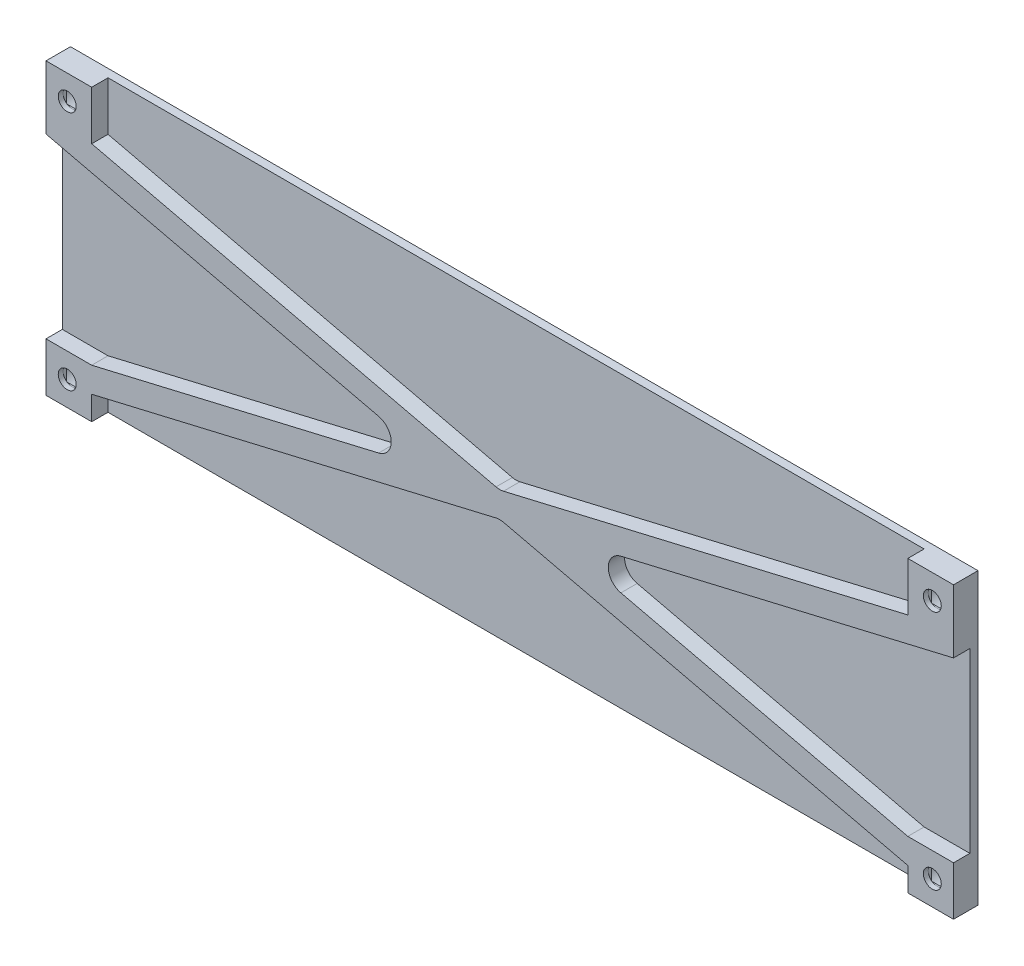
from build123d import *

# Parameters (mm, degrees)
SKETCH1_W                       = 112
SKETCH1_H                       = 35.5
BOSS_EXTRUDE1_DEPTH             = 1
SKETCH2_W                       = 6
SKETCH2_H                       = 6
BOSS_EXTRUDE2_DEPTH             = 2
SKETCH3_R                       = 1.1
CUT_EXTRUDE1_DEPTH              = 4
SKETCH4_R                       = 2
CUT_EXTRUDE2_DEPTH              = 2
CUT_EXTRUDE3_DEPTH              = 0.2
SKETCH6_W                       = 2.2
SKETCH6_H                       = 2.2
CUT_EXTRUDE4_DEPTH              = 0.2
MIRROR2_COPY_1_DEPTH            = 0.2
MIRROR2_COPY_2_SKETCH_W         = 2.2
MIRROR2_COPY_2_SKETCH_H         = 2.2
MIRROR2_COPY_2_DEPTH            = 0.2
SKETCH7_W                       = 0.4
SKETCH7_H                       = 35.5
CUT_EXTRUDE5_DEPTH              = 4
AUFSATZ_LINEAR_AUSTRAGEN2_DEPTH = 2
VERRUNDUNG1_R                   = 2


with BuildPart() as part:
    # Sketch1 → Boss-Extrude1 (new body)
    with BuildSketch(Plane.XY):
        Rectangle(SKETCH1_W, SKETCH1_H)
    extrude(amount=BOSS_EXTRUDE1_DEPTH)

    # Sketch2 → Boss-Extrude2 (add)
    with BuildSketch(Plane.XY.offset(1)):
        with Locations((-53, 14.75)):
            Rectangle(SKETCH2_W, SKETCH2_H)
        with Locations((-53, -14.75)):
            Rectangle(SKETCH2_W, SKETCH2_H)
        with Locations((53, -14.75)):
            Rectangle(SKETCH2_W, SKETCH2_H)
        with Locations((53, 14.75)):
            Rectangle(SKETCH2_W, SKETCH2_H)
    extrude(amount=BOSS_EXTRUDE2_DEPTH)

    # Sketch3 → Cut-Extrude1 (cut, through all)
    with BuildSketch(Plane.XY.offset(3)):
        with Locations((-53, 14.75)):
            Circle(SKETCH3_R)
        with Locations((-53, -14.75)):
            Circle(SKETCH3_R)
        with Locations((53, -14.75)):
            Circle(SKETCH3_R)
        with Locations((53, 14.75)):
            Circle(SKETCH3_R)
    extrude(amount=-CUT_EXTRUDE1_DEPTH, mode=Mode.SUBTRACT)

    # Sketch4 → Cut-Extrude2 (cut)
    with BuildSketch(Plane(origin=(0, 0, 0), x_dir=(-1, 0, 0), z_dir=(0, 0, -1))):
        with Locations((-53, 14.75)):
            Circle(SKETCH4_R)
        with Locations((-53, -14.75)):
            Circle(SKETCH4_R)
        with Locations((53, 14.75)):
            Circle(SKETCH4_R)
        with Locations((53, -14.75)):
            Circle(SKETCH4_R)
    extrude(amount=-CUT_EXTRUDE2_DEPTH, mode=Mode.SUBTRACT)

    # Sketch5 → Cut-Extrude3 (cut)
    with BuildSketch(Plane(origin=(0, 0, 2), x_dir=(-1, 0, 0), z_dir=(0, 0, -1))):
        with BuildLine():
            Line((-54.1, 13.079670691), (-54.1, 16.420329309))
            ThreePointArc((-54.1, 16.420329309), (-53, 16.75), (-51.9, 16.420329309))
            Line((-51.9, 16.420329309), (-51.9, 13.079670691))
            ThreePointArc((-51.9, 13.079670691), (-53, 12.75), (-54.1, 13.079670691))
        make_face()
    cut_extrude3 = extrude(amount=-CUT_EXTRUDE3_DEPTH, mode=Mode.SUBTRACT)

    # Sketch6 → Cut-Extrude4 (cut)
    with BuildSketch(Plane(origin=(0, 0, 2.2), x_dir=(-1, 0, 0), z_dir=(0, 0, -1))):
        with Locations((-53, 14.75)):
            Rectangle(SKETCH6_W, SKETCH6_H)
    cut_extrude4 = extrude(amount=-CUT_EXTRUDE4_DEPTH, mode=Mode.SUBTRACT)

    # Mirror1: Cut-Extrude3, Cut-Extrude4 across plane
    add(cut_extrude3.mirror(Plane(origin=(0, 0, 0), x_dir=(0, 0, 1), z_dir=(1, 0, 0))), mode=Mode.SUBTRACT)
    add(cut_extrude4.mirror(Plane(origin=(0, 0, 0), x_dir=(0, 0, 1), z_dir=(1, 0, 0))), mode=Mode.SUBTRACT)

    # Mirror2: Cut-Extrude3, Cut-Extrude4 across plane
    add(cut_extrude3.mirror(Plane.ZX), mode=Mode.SUBTRACT)
    add(cut_extrude4.mirror(Plane.ZX), mode=Mode.SUBTRACT)

    # Mirror2 copy 1 sketch → Mirror2 copy 1 (cut)
    with BuildSketch(Plane(origin=(0, 0, 2), x_dir=(1, 0, 0), z_dir=(0, 0, -1))):
        with BuildLine():
            Line((-54.1, 13.079670691), (-54.1, 16.420329309))
            ThreePointArc((-54.1, 16.420329309), (-53, 16.75), (-51.9, 16.420329309))
            Line((-51.9, 16.420329309), (-51.9, 13.079670691))
            ThreePointArc((-51.9, 13.079670691), (-53, 12.75), (-54.1, 13.079670691))
        make_face()
    extrude(amount=-MIRROR2_COPY_1_DEPTH, mode=Mode.SUBTRACT)

    # Mirror2 copy 2 sketch → Mirror2 copy 2 (cut)
    with BuildSketch(Plane(origin=(0, 0, 2.2), x_dir=(1, 0, 0), z_dir=(0, 0, -1))):
        with Locations((-53, 14.75)):
            Rectangle(MIRROR2_COPY_2_SKETCH_W, MIRROR2_COPY_2_SKETCH_H)
    extrude(amount=-MIRROR2_COPY_2_DEPTH, mode=Mode.SUBTRACT)

    # Sketch7 → Cut-Extrude5 (cut, through all)
    with BuildSketch(Plane(origin=(0, 0, 0), x_dir=(-1, 0, 0), z_dir=(0, 0, -1))):
        with Locations((-55.8, 0)):
            Rectangle(SKETCH7_W, SKETCH7_H)
        with Locations((55.8, 0)):
            Rectangle(SKETCH7_W, SKETCH7_H)
    extrude(amount=-CUT_EXTRUDE5_DEPTH, mode=Mode.SUBTRACT)

    # Skizze5 → Aufsatz-Linear austragen2 (add)
    with BuildSketch(Plane.XY.offset(1)):
        Polygon((-50, 11.75), (0, 0), (50, 11.75), (55.6, 11.75), (55.6, 9.984275645), (6.55686033, -1.540862177), (50, -11.75), (50, -14.831724355), (0, -3.081724355), (-50, -14.831724355), (-50, -11.75), (-6.55686033, -1.540862177), (-55.6, 9.984275645), (-55.6, 11.75), align=None)
    extrude(amount=AUFSATZ_LINEAR_AUSTRAGEN2_DEPTH)

    # Verrundung1
    verrundung1_edges = [part.edges().sort_by_distance(p)[0] for p in [
        (-6.55686033, -1.540862177, 2),
        (0, -3.081724355, 2),
        (6.55686033, -1.540862177, 2),
        (0, 0, 2),
    ]]
    fillet(verrundung1_edges, radius=VERRUNDUNG1_R)


solid = part.part
